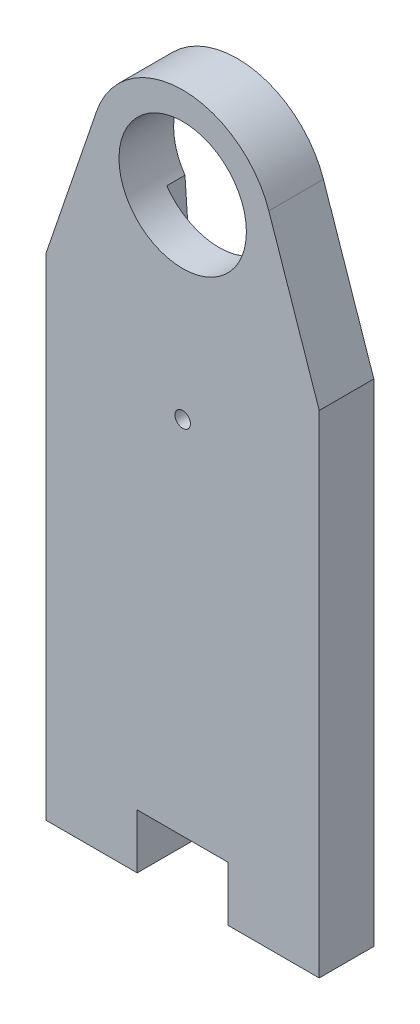
from build123d import *

# Parameters (mm, degrees)
CORTE_EXTERIOR_R        = 0.425
CORTE_EXTERIOR_R_2      = 3.500002336
SALIENTE_EXTRUIR3_DEPTH = 3
CORTAR_EXTRUIR2_DEPTH   = 1


with BuildPart() as part:
    # Corte exterior → Saliente-Extruir3 (new body)
    with BuildSketch(Plane.XY):
        with BuildLine():
            Line((40.5, 11.75), (35.5, 11.75))
            Line((35.5, 11.75), (35.5, 38.75))
            Line((35.5, 38.75), (38.267721236, 46.864167804))
            ThreePointArc((38.267721236, 46.864167804), (43, 50.25), (47.732278764, 46.864167804))
            Line((47.732278764, 46.864167804), (50.5, 38.75))
            Line((50.5, 38.75), (50.5, 24.75))
            Line((50.5, 24.75), (50.5, 11.75))
            Line((50.5, 11.75), (45.5, 11.75))
            Line((45.5, 11.75), (45.5, 14.75))
            Line((45.5, 14.75), (40.5, 14.75))
            Line((40.5, 14.75), (40.5, 11.75))
        make_face()
        with Locations((43, 34.577770546)):
            Circle(CORTE_EXTERIOR_R, mode=Mode.SUBTRACT)
        with Locations((43, 45.25)):
            Circle(CORTE_EXTERIOR_R_2, mode=Mode.SUBTRACT)
    extrude(amount=SALIENTE_EXTRUIR3_DEPTH)

    # Grabado Superficie → Cortar-Extruir2 (cut)
    with BuildSketch(Plane.XY):
        with BuildLine():
            Line((41.004825427, 30.611153235), (40.125, 43.253905976))
            ThreePointArc((40.125, 43.253905976), (43, 41.749997664), (45.875, 43.253905976))
            Line((45.875, 43.253905976), (44.995174573, 30.611153235))
            ThreePointArc((44.995174573, 30.611153235), (43, 28.75), (41.004825427, 30.611153235))
        make_face()
    extrude(amount=CORTAR_EXTRUIR2_DEPTH, mode=Mode.SUBTRACT)


solid = part.part
